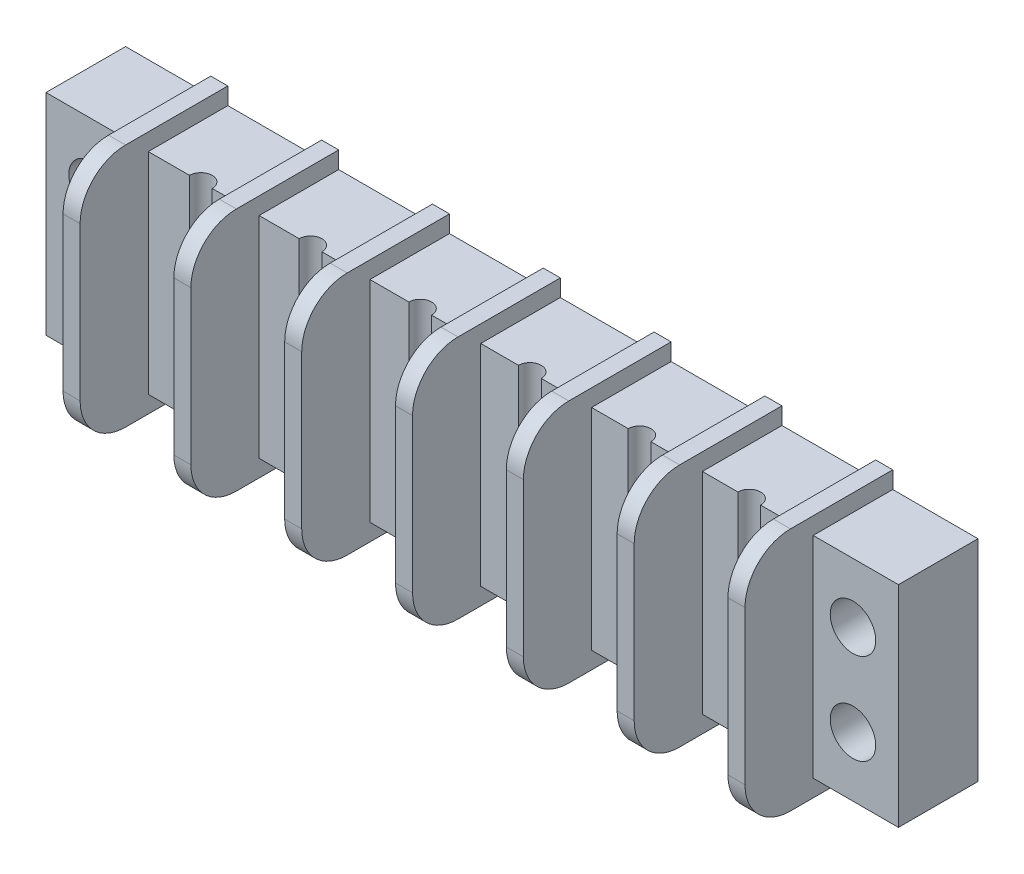
from build123d import *

# Parameters (mm, degrees)
ESQUISSE1_W                = 75
ESQUISSE1_H                = 18.5
BOSS_EXTRU_1_DEPTH         = 7
ENL_V_MAT_EXTRU_1_REACH    = 9
ESQUISSE2_R                = 2
ESQUISSE3_W                = 1.5
ESQUISSE3_H                = 21.5
BOSS_EXTRU_2_DEPTH         = 13
CONG_1_R                   = 4
ESQUISSE4_R                = 1
ENL_V_MAT_EXTRU_2_DEPTH    = 18.5
R_P_TITION_LIN_AIRE1_COUNT = 6
R_P_TITION_LIN_AIRE1_PITCH = 9.65


with BuildPart() as part:
    # Esquisse1 → Boss.-Extru.1 (new body)
    with BuildSketch(Plane.XY):
        with Locations((8.254716981, 3.839622642)):
            Rectangle(ESQUISSE1_W, ESQUISSE1_H)
    extrude(amount=BOSS_EXTRU_1_DEPTH)

    # Esquisse2 → Enlèv. mat.-Extru.1 (cut, up to next)
    with BuildSketch(Plane(origin=(0, 0, 0), x_dir=(-1, 0, 0), z_dir=(0, 0, -1)), mode=Mode.PRIVATE) as enl_v_mat_extru_1_sk1:
        with Locations((-41.754716981, 7.839622642)):
            Circle(ESQUISSE2_R)
    enl_v_mat_extru_1_tool1 = extrude(enl_v_mat_extru_1_sk1.sketch, amount=-ENL_V_MAT_EXTRU_1_REACH, mode=Mode.PRIVATE) & part.part
    add(enl_v_mat_extru_1_tool1.solids().sort_by_distance((41.754717, 7.839623, 0))[0], mode=Mode.SUBTRACT)
    # Esquisse2 → Enlèv. mat.-Extru.1 (cut, up to next)
    with BuildSketch(Plane(origin=(0, 0, 0), x_dir=(-1, 0, 0), z_dir=(0, 0, -1)), mode=Mode.PRIVATE) as enl_v_mat_extru_1_sk2:
        with Locations((-41.754716981, -0.160377358)):
            Circle(ESQUISSE2_R)
    enl_v_mat_extru_1_tool2 = extrude(enl_v_mat_extru_1_sk2.sketch, amount=-ENL_V_MAT_EXTRU_1_REACH, mode=Mode.PRIVATE) & part.part
    add(enl_v_mat_extru_1_tool2.solids().sort_by_distance((41.754717, -0.160377, 0))[0], mode=Mode.SUBTRACT)
    # Esquisse2 → Enlèv. mat.-Extru.1 (cut, up to next)
    with BuildSketch(Plane(origin=(0, 0, 0), x_dir=(-1, 0, 0), z_dir=(0, 0, -1)), mode=Mode.PRIVATE) as enl_v_mat_extru_1_sk3:
        with Locations((25.245283019, -0.160377358)):
            Circle(ESQUISSE2_R)
    enl_v_mat_extru_1_tool3 = extrude(enl_v_mat_extru_1_sk3.sketch, amount=-ENL_V_MAT_EXTRU_1_REACH, mode=Mode.PRIVATE) & part.part
    add(enl_v_mat_extru_1_tool3.solids().sort_by_distance((-25.245283, -0.160377, 0))[0], mode=Mode.SUBTRACT)
    # Esquisse2 → Enlèv. mat.-Extru.1 (cut, up to next)
    with BuildSketch(Plane(origin=(0, 0, 0), x_dir=(-1, 0, 0), z_dir=(0, 0, -1)), mode=Mode.PRIVATE) as enl_v_mat_extru_1_sk4:
        with Locations((25.245283019, 7.839622642)):
            Circle(ESQUISSE2_R)
    enl_v_mat_extru_1_tool4 = extrude(enl_v_mat_extru_1_sk4.sketch, amount=-ENL_V_MAT_EXTRU_1_REACH, mode=Mode.PRIVATE) & part.part
    add(enl_v_mat_extru_1_tool4.solids().sort_by_distance((-25.245283, 7.839623, 0))[0], mode=Mode.SUBTRACT)

    # Esquisse3 → Boss.-Extru.2 (add)
    with BuildSketch(Plane(origin=(0, 0, 0), x_dir=(-1, 0, 0), z_dir=(0, 0, -1))):
        with Locations((-37.504716981, 3.839622642)):
            Rectangle(ESQUISSE3_W, ESQUISSE3_H)
        with Locations((-27.754716981, 3.839622642)):
            Rectangle(ESQUISSE3_W, ESQUISSE3_H)
        with Locations((-18.004716981, 3.839622642)):
            Rectangle(ESQUISSE3_W, ESQUISSE3_H)
        with Locations((-8.254716981, 3.839622642)):
            Rectangle(ESQUISSE3_W, ESQUISSE3_H)
        with Locations((1.495283019, 3.839622642)):
            Rectangle(ESQUISSE3_W, ESQUISSE3_H)
        with Locations((11.245283019, 3.839622642)):
            Rectangle(ESQUISSE3_W, ESQUISSE3_H)
        with Locations((20.995283019, 3.839622642)):
            Rectangle(ESQUISSE3_W, ESQUISSE3_H)
    extrude(amount=-BOSS_EXTRU_2_DEPTH)

    # Congé1
    cong_1_edges = [part.edges().sort_by_distance(p)[0] for p in [
        (8.254716981, -6.910377358, 13),
        (8.254716981, 14.589622642, 13),
        (-1.495283019, -6.910377358, 13),
        (-1.495283019, 14.589622642, 13),
        (-11.245283019, -6.910377358, 13),
        (-11.245283019, 14.589622642, 13),
        (-20.995283019, -6.910377358, 13),
        (-20.995283019, 14.589622642, 13),
        (37.504716981, 14.589622642, 13),
        (37.504716981, -6.910377358, 13),
        (27.754716981, -6.910377358, 13),
        (27.754716981, 14.589622642, 13),
        (18.004716981, -6.910377358, 13),
        (18.004716981, 14.589622642, 13),
    ]]
    fillet(cong_1_edges, radius=CONG_1_R)

    # Esquisse4 → Enlèv. mat.-Extru.2 (cut)
    with BuildSketch(Plane.XZ.offset(5.410377358)):
        with Locations((32.629716981, 7)):
            Circle(ESQUISSE4_R)
    enl_v_mat_extru_2 = extrude(amount=-ENL_V_MAT_EXTRU_2_DEPTH, mode=Mode.SUBTRACT)

    # Répétition linéaire1: Enlèv. mat.-Extru.2 ×6
    with Locations(*[(-i * R_P_TITION_LIN_AIRE1_PITCH, 0, 0) for i in range(1, R_P_TITION_LIN_AIRE1_COUNT)]):
        add(enl_v_mat_extru_2, mode=Mode.SUBTRACT)


solid = part.part
